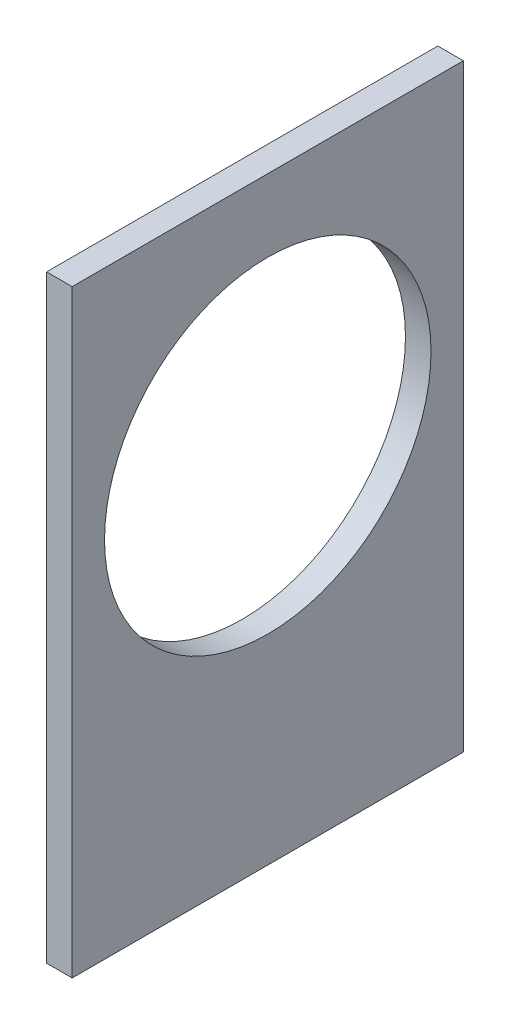
from build123d import *

# Parameters (mm, degrees)
SKETCH1_W           = 49
SKETCH1_H           = 75
BOSS_EXTRUDE1_DEPTH = 3.2
CUT_EXTRUDE1_REACH  = 5.2
SKETCH2_R           = 20.445


with BuildPart() as part:
    # Sketch1 → Boss-Extrude1 (new body)
    with BuildSketch(Plane(origin=(0, 0, 0), x_dir=(0, 0, -1), z_dir=(1, 0, 0))):
        with Locations((24.5, 37.5)):
            Rectangle(SKETCH1_W, SKETCH1_H)
    extrude(amount=BOSS_EXTRUDE1_DEPTH)

    # Sketch2 → Cut-Extrude1 (cut, up to next)
    with BuildSketch(Plane(origin=(3.2, 0, 0), x_dir=(0, 0, -1), z_dir=(1, 0, 0)), mode=Mode.PRIVATE) as cut_extrude1_sk1:
        with Locations((24.5, 45.495825453)):
            Circle(SKETCH2_R)
    cut_extrude1_tool1 = extrude(cut_extrude1_sk1.sketch, amount=-CUT_EXTRUDE1_REACH, mode=Mode.PRIVATE) & part.part
    add(cut_extrude1_tool1.solids().sort_by_distance((3.2, 45.495825, -24.5))[0], mode=Mode.SUBTRACT)


solid = part.part
